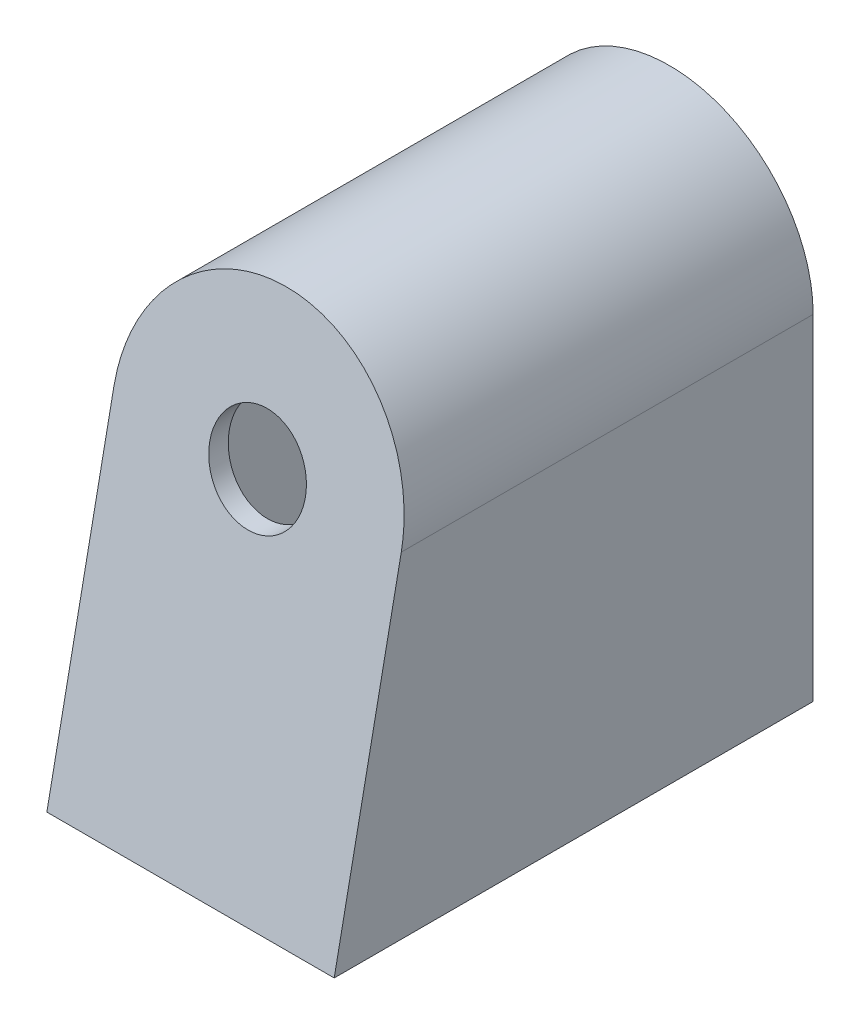
from build123d import *

# Parameters (mm, degrees)
ESQUISSE1_R                  = 5
BOSS_EXTRU_1_DEPTH           = 50
ENL_V_MAT_EXTRU_1_DEPTH      = 16
ENL_V_MAT_EXTRU_1_DEPTH_BACK = 16
ENL_V_MAT_EXTRU_2_REACH      = 52


with BuildPart() as part:
    # Esquisse1 → Boss.-Extru.1 (new body)
    with BuildSketch(Plane.XY):
        with BuildLine():
            Line((-15, -17.5), (15, -17.5))
            Line((15, -17.5), (15, 17.5))
            ThreePointArc((15, 17.5), (0, 32.5), (-15, 17.5))
            Line((-15, 17.5), (-15, -17.5))
        make_face()
        with Locations((0, 17.5)):
            Circle(ESQUISSE1_R, mode=Mode.SUBTRACT)
    extrude(amount=-BOSS_EXTRU_1_DEPTH)

    # Esquisse2 → Enlèv. mat.-Extru.1 (cut, two sides)
    with BuildSketch(Plane(origin=(0, 0, 0), x_dir=(0, 0, -1), z_dir=(1, 0, 0))) as enl_v_mat_extru_1_sk:
        Polygon((0, -17.5), (10, 32.5), (0, 32.5), align=None)
    extrude(amount=ENL_V_MAT_EXTRU_1_DEPTH, mode=Mode.SUBTRACT)
    extrude(enl_v_mat_extru_1_sk.sketch, amount=-ENL_V_MAT_EXTRU_1_DEPTH_BACK, mode=Mode.SUBTRACT)

    # Enlèv. mat.-Extru.2: up to this plane
    enl_v_mat_extru_2_end = Plane(origin=(-15, -17.89223227, -1.961161351), z_dir=(0, -0.196116135, -0.980580676))
    # Esquisse3 → Enlèv. mat.-Extru.2 (cut, up to the surface)
    with BuildSketch(Plane(origin=(0, 0, -50), x_dir=(-1, 0, 0), z_dir=(0, 0, -1)), mode=Mode.PRIVATE) as enl_v_mat_extru_2_sk1:
        with BuildLine():
            Line((-13, 17.5), (-13, -15.5))
            Line((-13, -15.5), (13, -15.5))
            Line((13, -15.5), (13, 17.5))
            ThreePointArc((13, 17.5), (0, 30.5), (-13, 17.5))
        make_face()
    enl_v_mat_extru_2_tool1 = split(extrude(enl_v_mat_extru_2_sk1.sketch, amount=-ENL_V_MAT_EXTRU_2_REACH, mode=Mode.PRIVATE), bisect_by=enl_v_mat_extru_2_end, keep=Keep.BOTH, mode=Mode.PRIVATE)
    add(enl_v_mat_extru_2_tool1.solids().sort_by_distance((0, 6.202507, -50))[0], mode=Mode.SUBTRACT)


solid = part.part
